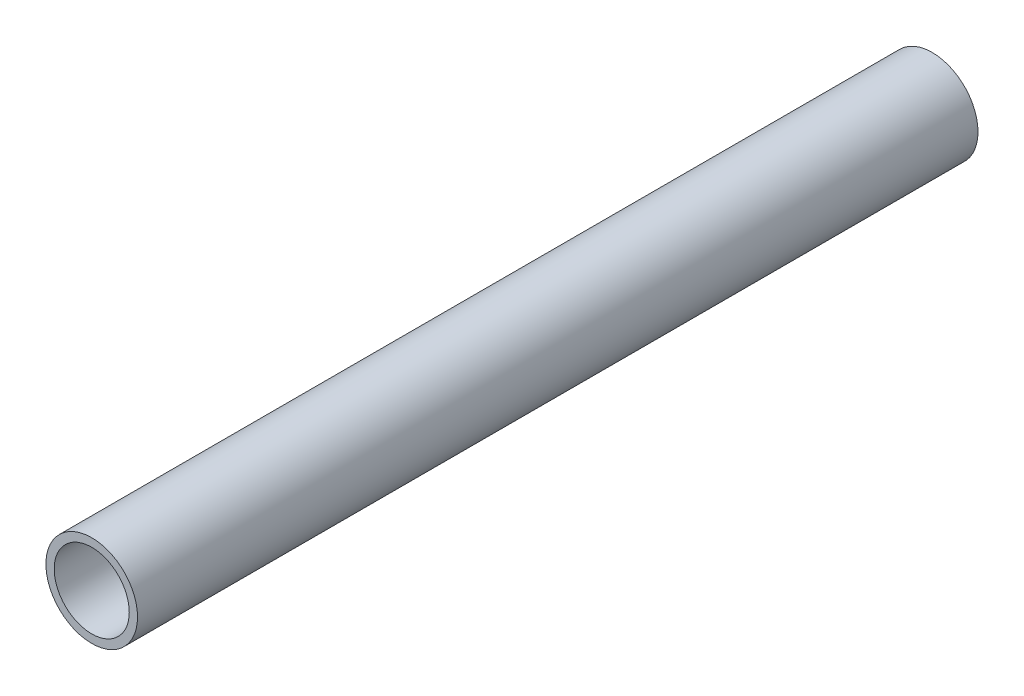
from build123d import *

# Parameters (mm, degrees)
SZKIC1_R                    = 7.75
SZKIC1_R_2                  = 6.35
DODANIE_WYCI_GNI_CIE1_DEPTH = 142.2


with BuildPart() as part:
    # Szkic1 → Dodanie-wyciągnięcie1 (new body)
    with BuildSketch(Plane.XY):
        Circle(SZKIC1_R)
        Circle(SZKIC1_R_2, mode=Mode.SUBTRACT)
    extrude(amount=DODANIE_WYCI_GNI_CIE1_DEPTH)


solid = part.part
